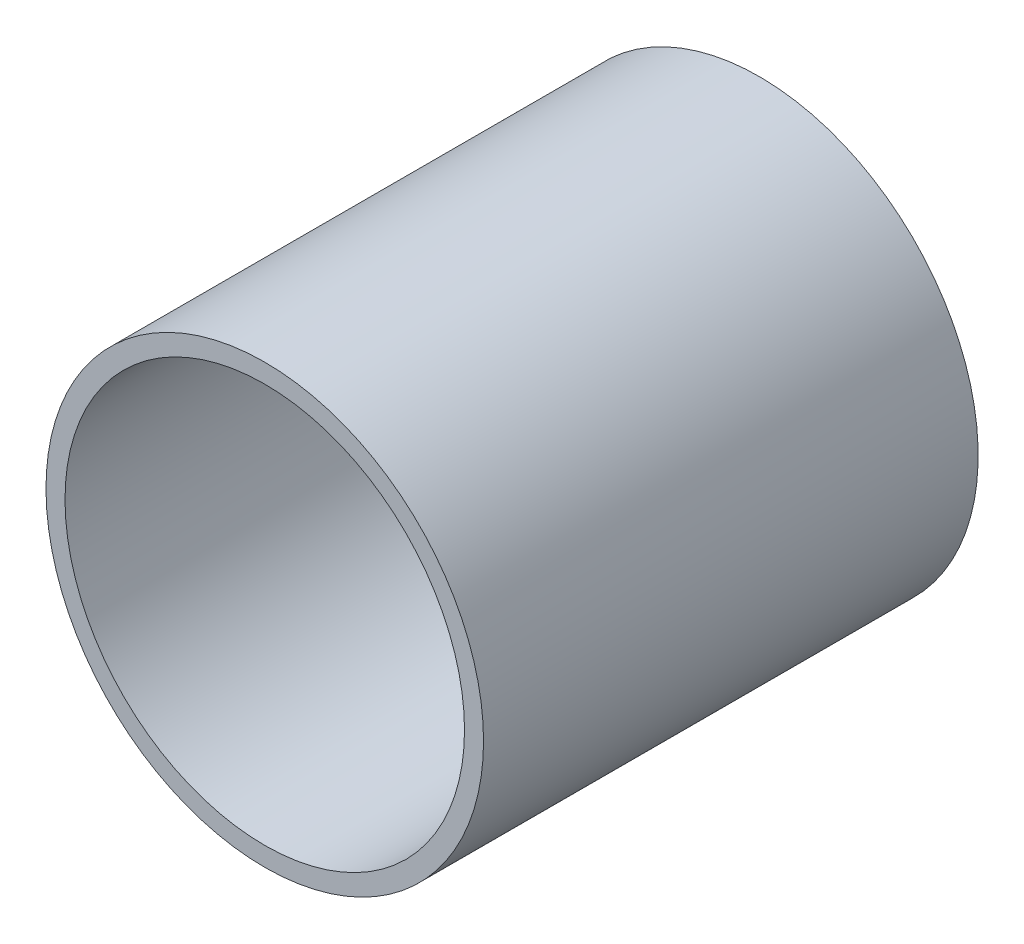
from build123d import *

# Parameters (mm, degrees)
SKETCH2_R           = 115
SKETCH2_R_2         = 105
BOSS_EXTRUDE1_DEPTH = 260
CUT_EXTRUDE1_REACH  = 117
SKETCH3_W           = 2
SKETCH3_H           = 15


with BuildPart() as part:
    # Sketch2 → Boss-Extrude1 (new body)
    with BuildSketch(Plane.XY):
        Circle(SKETCH2_R)
        Circle(SKETCH2_R_2, mode=Mode.SUBTRACT)
    extrude(amount=BOSS_EXTRUDE1_DEPTH)

    # Sketch3 → Cut-Extrude1 (cut, up to next)
    with BuildSketch(Plane(origin=(0, 0, 0), x_dir=(0, 0, -1), z_dir=(1, 0, 0)), mode=Mode.PRIVATE) as cut_extrude1_sk1:
        with Locations((-1, 0)):
            Rectangle(SKETCH3_W, SKETCH3_H)
    cut_extrude1_tool1 = extrude(cut_extrude1_sk1.sketch, amount=-CUT_EXTRUDE1_REACH, mode=Mode.PRIVATE) & part.part
    add(cut_extrude1_tool1.solids().sort_by_distance((0, 0, 1))[0], mode=Mode.SUBTRACT)


solid = part.part
